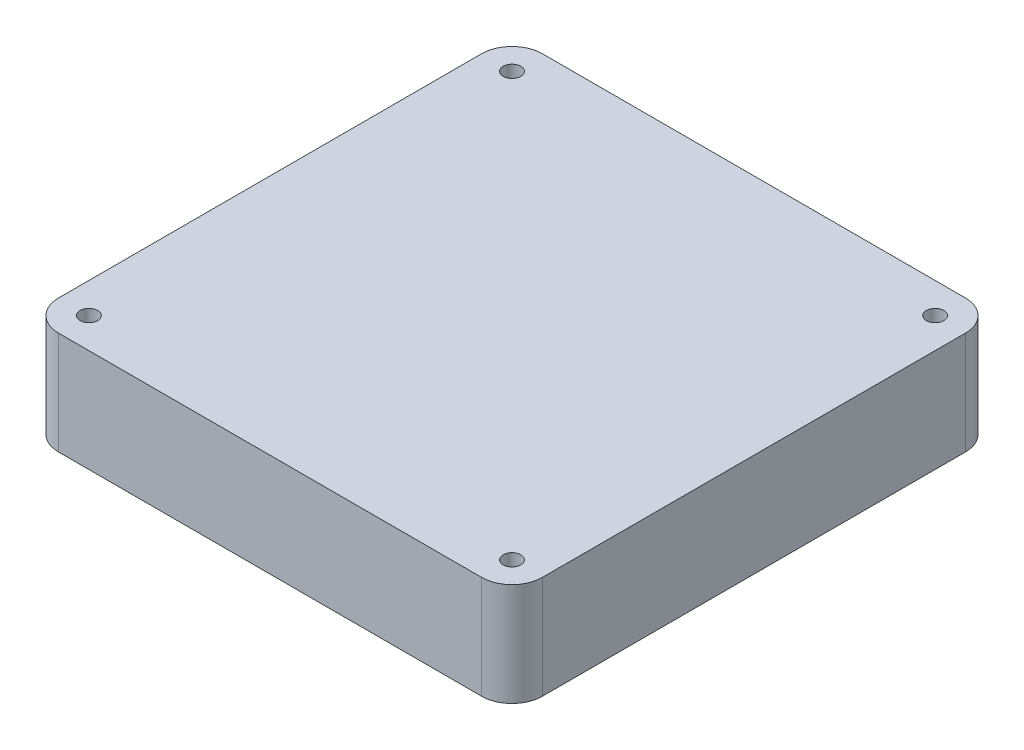
from build123d import *

# Parameters (mm, degrees)
SKETCH1_W           = 119.38
SKETCH1_H           = 119.38
BOSS_EXTRUDE1_DEPTH = 25.4
CUT_EXTRUDE1_REACH  = 27.4
SKETCH2_R           = 2.165
FILLET1_R           = 7.5
FILLET2_R           = 7.5
FILLET3_R           = 7.5


with BuildPart() as part:
    # Sketch1 → Boss-Extrude1 (new body)
    with BuildSketch(Plane(origin=(0, 0, 0), x_dir=(1, 0, 0), z_dir=(0, 1, 0))):
        Rectangle(SKETCH1_W, SKETCH1_H)
    extrude(amount=BOSS_EXTRUDE1_DEPTH)

    # Sketch2 → Cut-Extrude1 (cut, up to next)
    with BuildSketch(Plane(origin=(0, 25.4, 0), x_dir=(1, 0, 0), z_dir=(0, 1, 0)), mode=Mode.PRIVATE) as cut_extrude1_sk1:
        with Locations((-52.19, 52.19)):
            Circle(SKETCH2_R)
    cut_extrude1_tool1 = extrude(cut_extrude1_sk1.sketch, amount=-CUT_EXTRUDE1_REACH, mode=Mode.PRIVATE) & part.part
    add(cut_extrude1_tool1.solids().sort_by_distance((-52.19, 25.4, -52.19))[0], mode=Mode.SUBTRACT)
    # Sketch2 → Cut-Extrude1 (cut, up to next)
    with BuildSketch(Plane(origin=(0, 25.4, 0), x_dir=(1, 0, 0), z_dir=(0, 1, 0)), mode=Mode.PRIVATE) as cut_extrude1_sk2:
        with Locations((52.19, 52.19)):
            Circle(SKETCH2_R)
    cut_extrude1_tool2 = extrude(cut_extrude1_sk2.sketch, amount=-CUT_EXTRUDE1_REACH, mode=Mode.PRIVATE) & part.part
    add(cut_extrude1_tool2.solids().sort_by_distance((52.19, 25.4, -52.19))[0], mode=Mode.SUBTRACT)
    # Sketch2 → Cut-Extrude1 (cut, up to next)
    with BuildSketch(Plane(origin=(0, 25.4, 0), x_dir=(1, 0, 0), z_dir=(0, 1, 0)), mode=Mode.PRIVATE) as cut_extrude1_sk3:
        with Locations((52.19, -52.19)):
            Circle(SKETCH2_R)
    cut_extrude1_tool3 = extrude(cut_extrude1_sk3.sketch, amount=-CUT_EXTRUDE1_REACH, mode=Mode.PRIVATE) & part.part
    add(cut_extrude1_tool3.solids().sort_by_distance((52.19, 25.4, 52.19))[0], mode=Mode.SUBTRACT)
    # Sketch2 → Cut-Extrude1 (cut, up to next)
    with BuildSketch(Plane(origin=(0, 25.4, 0), x_dir=(1, 0, 0), z_dir=(0, 1, 0)), mode=Mode.PRIVATE) as cut_extrude1_sk4:
        with Locations((-52.19, -52.19)):
            Circle(SKETCH2_R)
    cut_extrude1_tool4 = extrude(cut_extrude1_sk4.sketch, amount=-CUT_EXTRUDE1_REACH, mode=Mode.PRIVATE) & part.part
    add(cut_extrude1_tool4.solids().sort_by_distance((-52.19, 25.4, 52.19))[0], mode=Mode.SUBTRACT)

    # Fillet1
    fillet1_edges = [part.edges().sort_by_distance(p)[0] for p in [
        (-59.69, 12.7, -59.69),
    ]]
    fillet(fillet1_edges, radius=FILLET1_R)

    # Fillet2
    fillet2_edges = [part.edges().sort_by_distance(p)[0] for p in [
        (59.69, 12.7, -59.69),
    ]]
    fillet(fillet2_edges, radius=FILLET2_R)

    # Fillet3
    fillet3_edges = [part.edges().sort_by_distance(p)[0] for p in [
        (59.69, 12.7, 59.69),
        (-59.69, 12.7, 59.69),
    ]]
    fillet(fillet3_edges, radius=FILLET3_R)


solid = part.part
